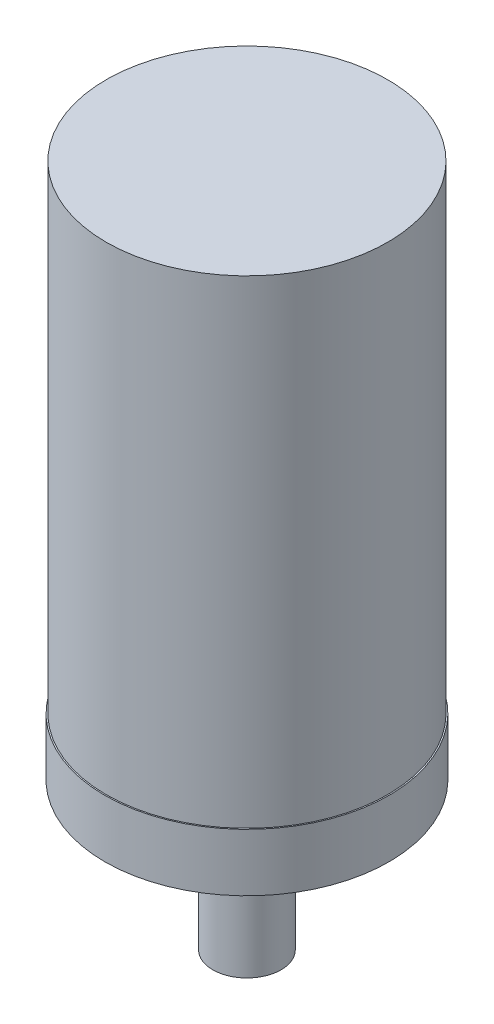
from build123d import *

# Parameters (mm, degrees)
CROQUIS1_R              = 9.5
CROQUIS1_R_2            = 8.2
SALIENTE_EXTRUIR1_DEPTH = 35
CROQUIS3_R              = 39.137042658
CROQUIS3_R_2            = 38.2
SALIENTE_EXTRUIR2_DEPTH = 130
CROQUIS4_R              = 39.137042658
SALIENTE_EXTRUIR3_DEPTH = 3


with BuildPart() as part:
    # Croquis1 → Saliente-Extruir1 (new body)
    with BuildSketch(Plane(origin=(0, 0, 0), x_dir=(1, 0, 0), z_dir=(0, 1, 0))):
        Circle(CROQUIS1_R)
        Circle(CROQUIS1_R_2, mode=Mode.SUBTRACT)
    extrude(amount=SALIENTE_EXTRUIR1_DEPTH)

    # Croquis2 → Revolución1 (revolve)
    with BuildSketch(Plane.XY):
        Polygon((-9.5, 35), (-39.5, 41), (-39.5, 57), (-38.2, 57), (-38.2, 42.065745074), (-8.2, 36.065745074), (-8.2, 35), align=None)
    revolve(axis=Axis((0, 35, 0), (0, -1, 0)))

    # Croquis3 → Saliente-Extruir2 (add)
    with BuildSketch(Plane(origin=(0, 57, 0), x_dir=(1, 0, 0), z_dir=(0, 1, 0))):
        Circle(CROQUIS3_R)
        Circle(CROQUIS3_R_2, mode=Mode.SUBTRACT)
    extrude(amount=SALIENTE_EXTRUIR2_DEPTH)

    # Croquis4 → Saliente-Extruir3 (add)
    with BuildSketch(Plane(origin=(0, 187, 0), x_dir=(1, 0, 0), z_dir=(0, 1, 0))):
        Circle(CROQUIS4_R)
    extrude(amount=SALIENTE_EXTRUIR3_DEPTH)


solid = part.part
